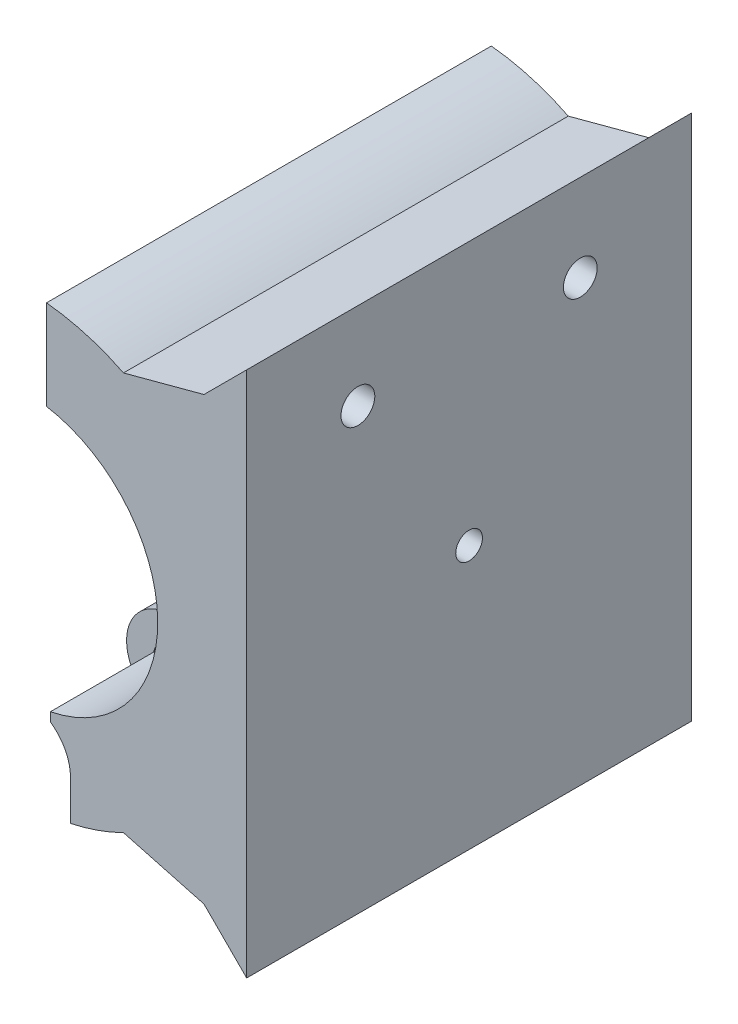
from build123d import *

# Parameters (mm, degrees)
SKETCH1_R           = 5
SKETCH1_R_2         = 2
BOSS_EXTRUDE1_DEPTH = 50
CUT_EXTRUDE13_DEPTH = 16.5
BOSS_EXTRUDE2_DEPTH = 50
SKETCH13_R          = 1.9
CUT_EXTRUDE12_DEPTH = 23.5
CUT_EXTRUDE14_DEPTH = 16.5
SKETCH20_R          = 1.5
CUT_EXTRUDE15_DEPTH = 26


with BuildPart() as part:
    # Sketch1 → Boss-Extrude1 (new body)
    with BuildSketch(Plane.XY):
        with Locations((0, -20)):
            Circle(SKETCH1_R)
        with Locations((0, -20)):
            Circle(SKETCH1_R_2, mode=Mode.SUBTRACT)
        with BuildLine():
            Line((2.5, 24.874685928), (2.5, 14.790199458))
            ThreePointArc((2.5, 14.790199458), (14.947457842, -1.254393904), (0, -15))
            ThreePointArc((0, -15), (3.535533906, -16.464466094), (5, -20))
            ThreePointArc((5, -20), (3.535533906, -23.535533906), (0, -25))
            ThreePointArc((0, -25), (24.968651828, -1.251569376), (2.5, 24.874685928))
        make_face()
    extrude(amount=BOSS_EXTRUDE1_DEPTH)

    # Sketch16 → Cut-Extrude13 (cut)
    with BuildSketch(Plane.XY.offset(50)):
        with BuildLine():
            Line((0, -25.2), (5.2, -25.2))
            Line((5.2, -25.2), (5.2, -20))
            ThreePointArc((5.2, -20), (-3.676955262, -16.323044738), (0, -25.2))
        make_face()
    cut_extrude13 = extrude(amount=-CUT_EXTRUDE13_DEPTH, mode=Mode.SUBTRACT)

    # Mirror2: Cut-Extrude13 across plane
    add(cut_extrude13.mirror(Plane(origin=(0, 0, 25), x_dir=(1, 0, 0), z_dir=(0, 0, -1))), mode=Mode.SUBTRACT)

    # Sketch17 → Boss-Extrude2 (add)
    with BuildSketch(Plane(origin=(0, 0, 0), x_dir=(-1, 0, 0), z_dir=(0, 0, -1))):
        Polygon((-20.2, 24.8), (-11.15099728, 22.375327029), (-20.2, 0), (-11.15099728, -22.375327029), (-20.2, -24.8), (-25, -29.6), (-25, 29.6), align=None)
    extrude(amount=-BOSS_EXTRUDE2_DEPTH)

    # Sketch13 → Cut-Extrude12 (cut, through all)
    with BuildSketch(Plane.ZY.offset(-2.5)):
        with Locations((37.5, 19.832442693)):
            Circle(SKETCH13_R)
        with Locations((12.5, 19.832442693)):
            Circle(SKETCH13_R)
    extrude(amount=-CUT_EXTRUDE12_DEPTH, mode=Mode.SUBTRACT)

    # Sketch19 → Cut-Extrude14 (cut)
    with BuildSketch(Plane.XY.offset(50)):
        with BuildLine():
            Line((2.937921703, -15.709473684), (2.937921703, -14.709473684))
            ThreePointArc((2.937921703, -14.709473684), (2.090334438, -14.853635984), (1.235879849, -14.949))
            ThreePointArc((1.235879849, -14.949), (2.121257859, -15.252341093), (2.937921703, -15.709473684))
        make_face()
    cut_extrude14 = extrude(amount=-CUT_EXTRUDE14_DEPTH, mode=Mode.SUBTRACT)

    # Mirror4: Cut-Extrude14 across plane
    add(cut_extrude14.mirror(Plane(origin=(0, 0, 25), x_dir=(1, 0, 0), z_dir=(0, 0, -1))), mode=Mode.SUBTRACT)

    # Sketch20 → Cut-Extrude15 (cut, through all)
    with BuildSketch(Plane(origin=(0, 0, 0), x_dir=(0, 0, -1), z_dir=(1, 0, 0))):
        with Locations((-25, 0)):
            Circle(SKETCH20_R)
    extrude(amount=CUT_EXTRUDE15_DEPTH, mode=Mode.SUBTRACT)


solid = part.part
